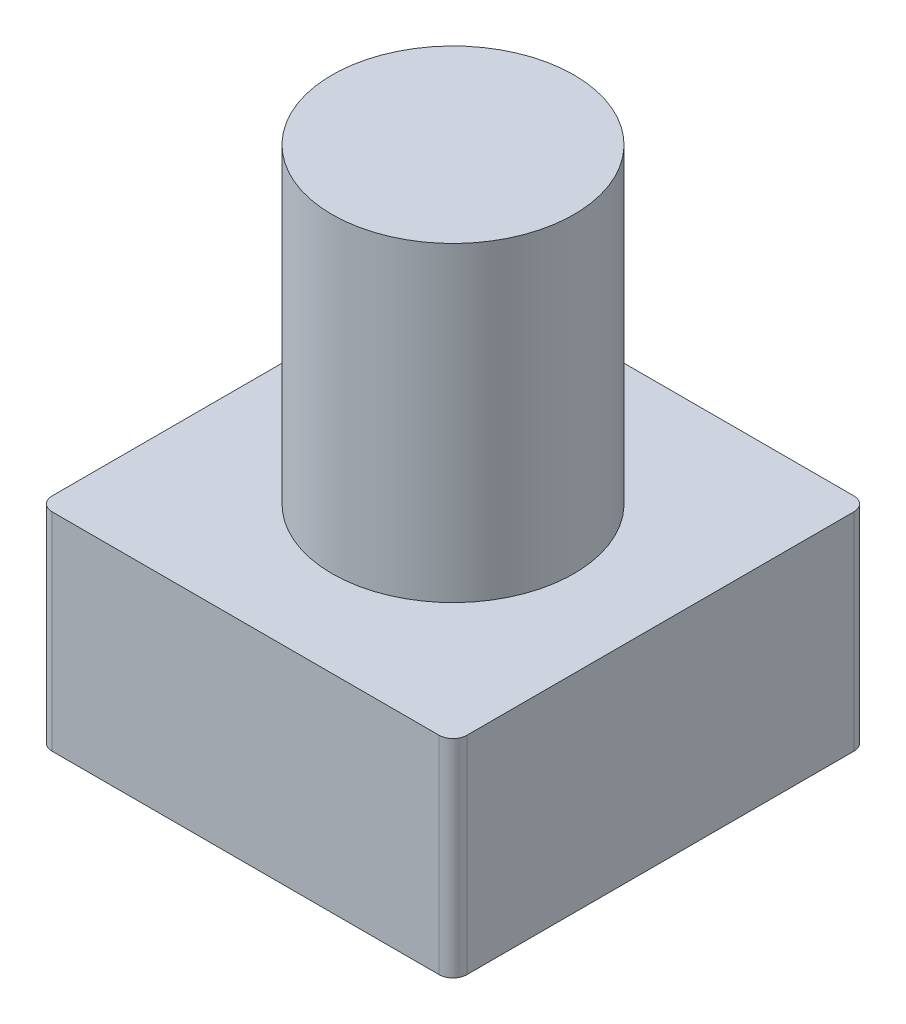
from build123d import *

# Parameters (mm, degrees)
EXTRUDE_1_DEPTH = 3
SKETCH_2_R      = 1.75
EXTRUDE_2_DEPTH = 4.5


with BuildPart() as part:
    # 草图1 → 凸台-拉伸1 (new body)
    with BuildSketch(Plane(origin=(0, 0, 0), x_dir=(1, 0, 0), z_dir=(0, 1, 0))):
        with BuildLine():
            Line((-2.8, -3), (2.8, -3))
            ThreePointArc((2.8, -3), (2.941421356, -2.941421356), (3, -2.8))
            Line((3, -2.8), (3, 2.8))
            ThreePointArc((3, 2.8), (2.941421356, 2.941421356), (2.8, 3))
            Line((2.8, 3), (-2.8, 3))
            ThreePointArc((-2.8, 3), (-2.941421356, 2.941421356), (-3, 2.8))
            Line((-3, 2.8), (-3, -2.8))
            ThreePointArc((-3, -2.8), (-2.941421356, -2.941421356), (-2.8, -3))
        make_face()
    extrude(amount=EXTRUDE_1_DEPTH)

    # 草图2 → 凸台-拉伸2 (add)
    with BuildSketch(Plane(origin=(0, 3, 0), x_dir=(1, 0, 0), z_dir=(0, 1, 0))):
        Circle(SKETCH_2_R)
    extrude(amount=EXTRUDE_2_DEPTH)


solid = part.part
